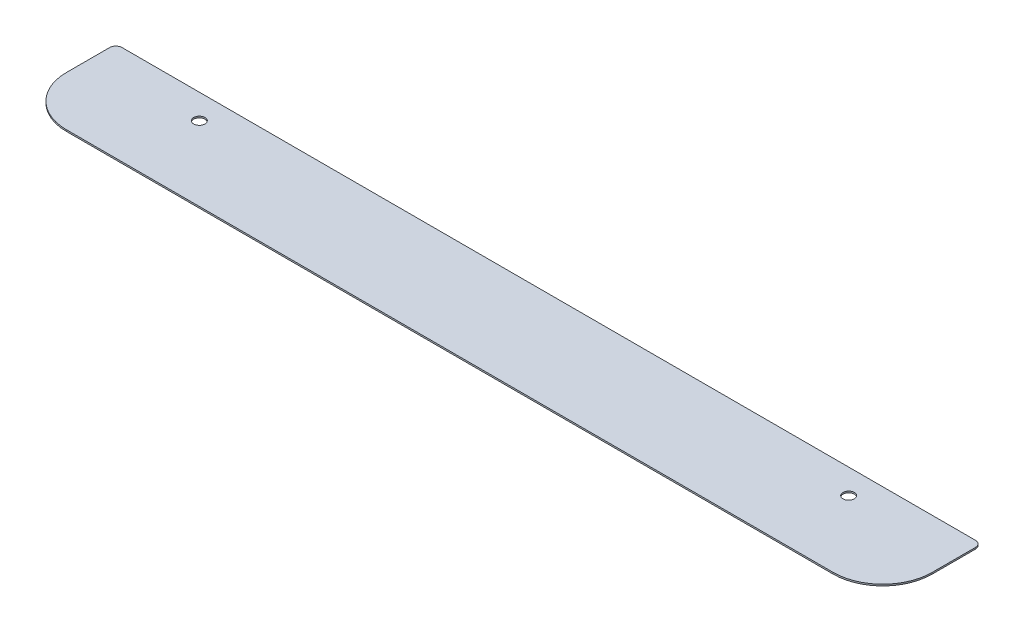
from build123d import *

# Parameters (mm, degrees)
SKETCH1_W                  = 444.5
SKETCH1_H                  = 50.8
BOSS_EXTRUDE1_DEPTH        = 0.79375
FILLET1_R                  = 25.4
FILLET2_R                  = 3.175
F_1_0_228_DIAMETER_HOLE1_D = 5.7912


with BuildPart() as part:
    # Sketch1 → Boss-Extrude1 (new body)
    with BuildSketch(Plane(origin=(0, 0, 0), x_dir=(1, 0, 0), z_dir=(0, 1, 0))):
        Rectangle(SKETCH1_W, SKETCH1_H)
    extrude(amount=BOSS_EXTRUDE1_DEPTH)

    # Fillet1
    fillet1_edges = [part.edges().sort_by_distance(p)[0] for p in [
        (222.25, 0.396875, 25.4),
        (-222.25, 0.396875, 25.4),
    ]]
    fillet(fillet1_edges, radius=FILLET1_R)

    # Fillet2
    fillet2_edges = [part.edges().sort_by_distance(p)[0] for p in [
        (-222.25, 0.396875, -25.4),
        (222.25, 0.396875, -25.4),
    ]]
    fillet(fillet2_edges, radius=FILLET2_R)

    # #1 (0.228) Diameter Hole1 (through all)
    with Locations(Plane(origin=(0, 0.79375, 0), x_dir=(1, 0, 0), z_dir=(0, 1, 0))):
        with Locations((166.6875, 12.7), (-166.6875, 12.7)):
            Hole(F_1_0_228_DIAMETER_HOLE1_D / 2)


solid = part.part
